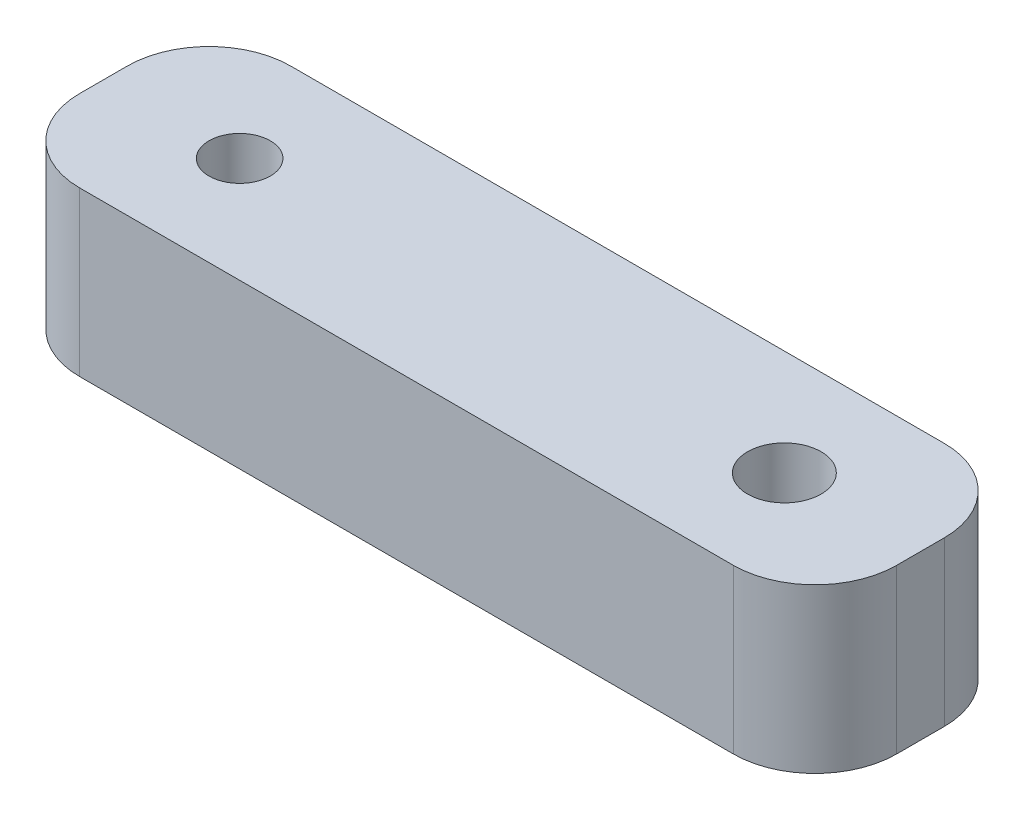
from build123d import *

# Parameters (mm, degrees)
BOSS_EXTRUDE1_DEPTH = 6
SKETCH2_R           = 1.125
SKETCH2_R_2         = 1.35
CUT_EXTRUDE1_DEPTH  = 7


with BuildPart() as part:
    # Sketch1 → Boss-Extrude1 (new body)
    with BuildSketch(Plane(origin=(0, 0, 0), x_dir=(1, 0, 0), z_dir=(0, 1, 0))):
        with BuildLine():
            Line((-12, 3.875), (12, 3.875))
            ThreePointArc((12, 3.875), (14.121320344, 2.996320344), (15, 0.875))
            Line((15, 0.875), (15, -0.875))
            ThreePointArc((15, -0.875), (14.121320344, -2.996320344), (12, -3.875))
            Line((12, -3.875), (-12, -3.875))
            ThreePointArc((-12, -3.875), (-14.121320344, -2.996320344), (-15, -0.875))
            Line((-15, -0.875), (-15, 0.875))
            ThreePointArc((-15, 0.875), (-14.121320344, 2.996320344), (-12, 3.875))
        make_face()
    extrude(amount=BOSS_EXTRUDE1_DEPTH)

    # Sketch2 → Cut-Extrude1 (cut, through all)
    with BuildSketch(Plane(origin=(0, 6, 0), x_dir=(1, 0, 0), z_dir=(0, 1, 0))):
        with Locations((-10, 0)):
            Circle(SKETCH2_R)
        with Locations((10, 0)):
            Circle(SKETCH2_R_2)
    extrude(amount=-CUT_EXTRUDE1_DEPTH, mode=Mode.SUBTRACT)


solid = part.part
